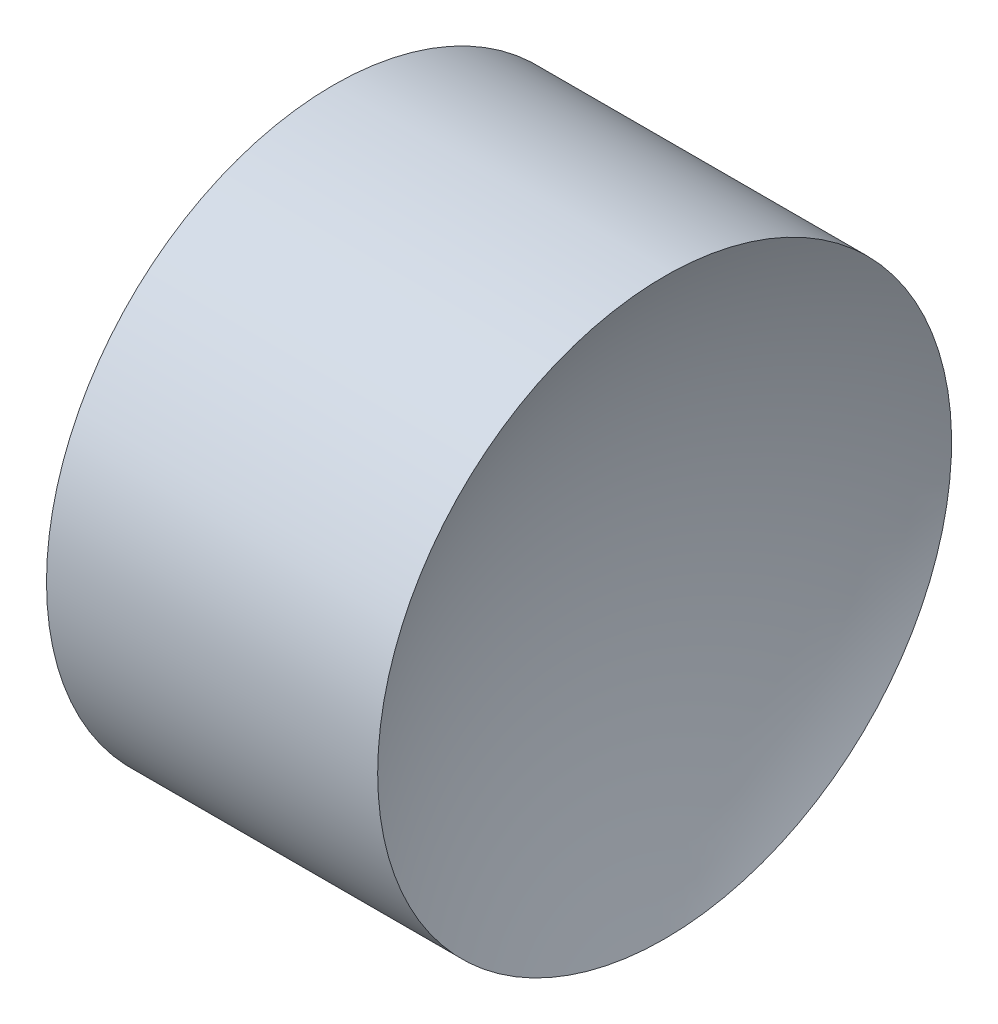
from build123d import *


with BuildPart() as part:
    # 草图1 → 旋转1 (revolve)
    with BuildSketch(Plane.XY, mode=Mode.PRIVATE) as revolve_1_sk:
        with BuildLine():
            Line((11.514118604, 6.522260287), (12.514118604, 6.522260287))
            ThreePointArc((12.514118604, 6.522260287), (12.606834957, 7.294215146), (12.879710201, 8.022260287))
            Line((12.879710201, 8.022260287), (12.014118604, 8.022260287))
            Line((12.014118604, 8.022260287), (11.148527006, 8.022260287))
            ThreePointArc((11.148527006, 8.022260287), (11.42140225, 7.294215146), (11.514118604, 6.522260287))
        make_face()
    revolve(revolve_1_sk.sketch.rotate(Axis((10.612465279, 6.522260287, 0), (1, 0, 0)), 90), axis=Axis((10.612465279, 6.522260287, 0), (1, 0, 0)))  # turned: the seam where the file's is


solid = part.part
